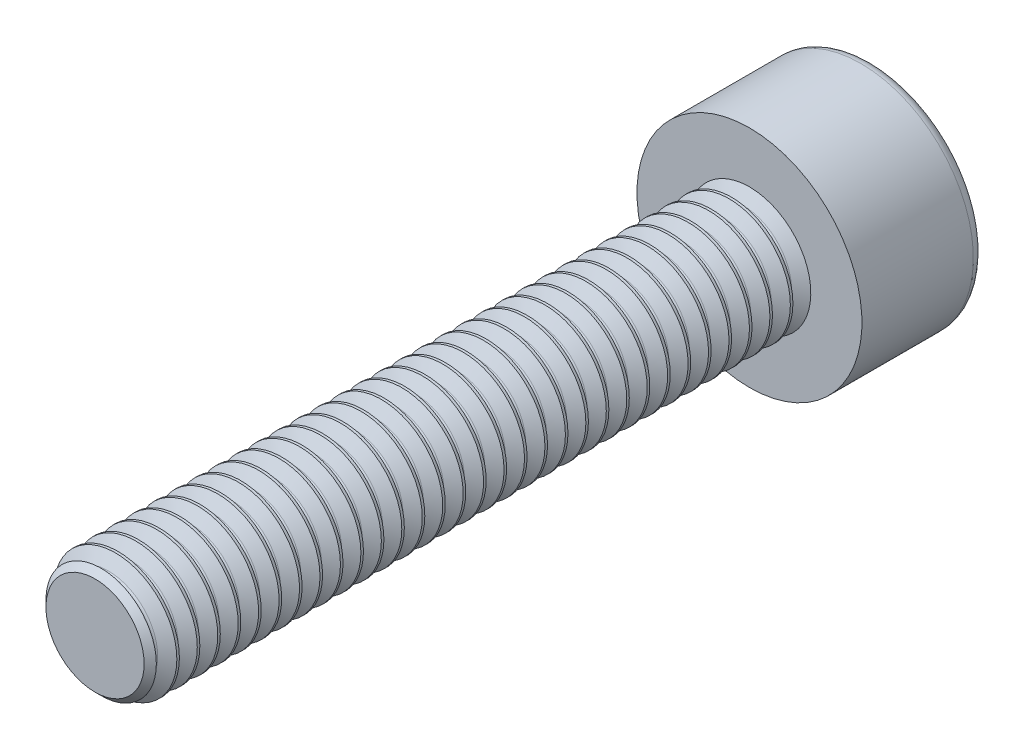
from build123d import *

# Parameters (mm, degrees)
SKETCH5_W           = 16
SKETCH5_H           = 1.5
THREAD_SIMPLE_COUNT = 33
THREAD_SIMPLE_PITCH = 0.5
SKETCH15_W          = 3
SKETCH15_H          = 2.75
CUT_HEAD_KEY_DEPTH  = 1.5


with BuildPart() as part:
    # Sketch5 → body (revolve)
    with BuildSketch(Plane(origin=(0, 0, 0), x_dir=(0, 0, -1), z_dir=(1, 0, 0))):
        with Locations((-8, 0.75)):
            Rectangle(SKETCH5_W, SKETCH5_H)
    revolve(axis=Axis((0, 0, 16), (0, 0, -1)))

    # Sketch11 → cut-chamfer-start (revolve, cut)
    with BuildSketch(Plane(origin=(0, 0, 0), x_dir=(0, 0, -1), z_dir=(1, 0, 0))):
        Polygon((-16, -1.5), (-16, -1.2), (-15.7, -1.5), align=None)
    revolve(axis=Axis((0, 0, 16), (0, 0, -1)), mode=Mode.SUBTRACT)

    # Sketch8 → thread-single (revolve, cut)
    with BuildSketch(Plane(origin=(0, 0, 0), x_dir=(0, 0, -1), z_dir=(1, 0, 0))):
        with BuildLine():
            Line((-0.4375, -1.5), (0, -1.5))
            Line((0, -1.5), (-0.171875, -1.202303767))
            ThreePointArc((-0.171875, -1.202303767), (-0.21875, -1.175240474), (-0.265625, -1.202303767))
            Line((-0.265625, -1.202303767), (-0.4375, -1.5))
        make_face()
    thread_single = revolve(axis=Axis((0, 0, 16), (0, 0, -1)), mode=Mode.SUBTRACT)

    # thread-simple: thread-single ×33
    with Locations(*[(0, 0, i * THREAD_SIMPLE_PITCH) for i in range(1, THREAD_SIMPLE_COUNT)]):
        add(thread_single, mode=Mode.SUBTRACT)

    # Sketch15 → body-head (revolve)
    with BuildSketch(Plane(origin=(0, 0, 0), x_dir=(0, 0, -1), z_dir=(1, 0, 0))):
        with Locations((1.5, -1.375)):
            Rectangle(SKETCH15_W, SKETCH15_H)
    revolve(axis=Axis((0, 0, -3), (0, 0, 1)))

    # Sketch19 → cut-head-profile (revolve, cut)
    with BuildSketch(Plane(origin=(0, 0, 0), x_dir=(0, 0, -1), z_dir=(1, 0, 0))):
        with BuildLine():
            Line((3, -2.75), (3, -2.475))
            ThreePointArc((3, -2.475), (2.919454365, -2.669454365), (2.725, -2.75))
            Line((2.725, -2.75), (3, -2.75))
        make_face()
    revolve(axis=Axis((0, 0, -3), (0, 0, 1)), mode=Mode.SUBTRACT)

    # Sketch25 → cut-head-key (cut)
    with BuildSketch(Plane.XY.offset(-3)):
        Polygon((0.721687836, 1.25), (-0.721687836, 1.25), (-1.443375673, 0), (-0.721687836, -1.25), (0.721687836, -1.25), (1.443375673, 0), align=None)
    extrude(amount=CUT_HEAD_KEY_DEPTH, mode=Mode.SUBTRACT)


solid = part.part
